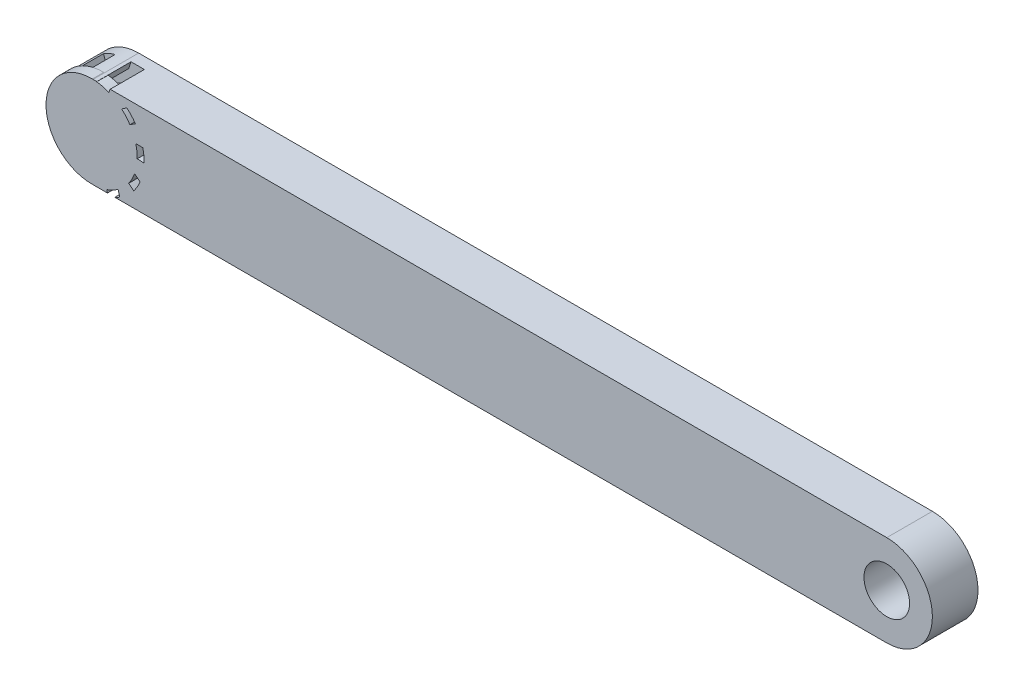
from build123d import *

# Parameters (mm, degrees)
SKETCH1_R           = 10
BOSS_EXTRUDE1_DEPTH = 20
BOSS_EXTRUDE2_DEPTH = 20
CUT_EXTRUDE1_DEPTH  = 15
SKETCH5_R           = 20
BOSS_EXTRUDE3_DEPTH = 5


with BuildPart() as part:
    # Sketch1 → Boss-Extrude1 (new body)
    with BuildSketch(Plane.XY):
        with BuildLine():
            Line((-71.370560529, 20), (276.629439471, 20))
            ThreePointArc((276.629439471, 20), (296.629439471, 0), (276.629439471, -20))
            Line((276.629439471, -20), (-71.370560529, -20))
            ThreePointArc((-71.370560529, -20), (-91.370560529, 0), (-71.370560529, 20))
        make_face()
        with Locations((-71.370560529, 0)):
            Circle(SKETCH1_R, mode=Mode.SUBTRACT)
        with Locations((276.629439471, 0)):
            Circle(SKETCH1_R, mode=Mode.SUBTRACT)
    extrude(amount=BOSS_EXTRUDE1_DEPTH)

    # Sketch2 → Boss-Extrude2 (add)
    with BuildSketch(Plane(origin=(0, 0, 0), x_dir=(-1, 0, 0), z_dir=(0, 0, -1))):
        with BuildLine():
            Line((71.370560529, -20), (71.370560529, -25))
            ThreePointArc((71.370560529, -25), (64.900084402, -24.148145657), (58.870560529, -21.650635095))
            Line((58.870560529, -21.650635095), (62.564306071, -17.956889553))
            ThreePointArc((62.564306071, -17.956889553), (66.850482602, -19.482527955), (71.370560529, -20))
        make_face()
    extrude(amount=BOSS_EXTRUDE2_DEPTH)

    # Sketch6 → Cut-Extrude1 (cut)
    with BuildSketch(Plane.XY.offset(20)):
        with BuildLine():
            ThreePointArc((-88.39401573, 13.427541495), (-86.445115044, 11.855559488), (-84.410885886, 10.395678313))
            ThreePointArc((-84.410885886, 10.395678313), (-82.694985814, 12.298884863), (-80.712431568, 13.922457124))
            ThreePointArc((-80.712431568, 13.922457124), (-81.560998495, 16.374699705), (-82.281198511, 18.867664093))
            ThreePointArc((-82.281198511, 18.867664093), (-79.798448631, 20.149575363), (-77.17323964, 21.106456352))
            ThreePointArc((-77.17323964, 21.106456352), (-76.520533705, 18.689161112), (-75.73290437, 16.312402533))
            ThreePointArc((-75.73290437, 16.312402533), (-73.22603531, 16.843548219), (-70.667803401, 16.991729622))
            ThreePointArc((-70.667803401, 16.991729622), (-69.912916442, 19.47441067), (-69.030242792, 21.914584175))
            ThreePointArc((-69.030242792, 21.914584175), (-66.268167407, 21.492348412), (-63.581888186, 20.723422265))
            ThreePointArc((-63.581888186, 20.723422265), (-64.474688485, 18.384138413), (-65.234506609, 15.998343424))
            ThreePointArc((-65.234506609, 15.998343424), (-62.894207335, 14.954548647), (-60.737455402, 13.570738932))
            ThreePointArc((-60.737455402, 13.570738932), (-58.667455717, 15.135558669), (-56.519059735, 16.59087795))
            ThreePointArc((-56.519059735, 16.59087795), (-54.532677763, 14.625774866), (-52.811395672, 12.424745236))
            ThreePointArc((-52.811395672, 12.424745236), (-54.908682835, 11.056999694), (-56.925723719, 9.57346089))
            ThreePointArc((-56.925723719, 9.57346089), (-55.645909011, 7.353419778), (-54.714442987, 4.966187222))
            ThreePointArc((-54.714442987, 4.966187222), (-52.120000099, 5.015437696), (-49.526496029, 4.930020252))
            ThreePointArc((-49.526496029, 4.930020252), (-49.074537869, 2.172652432), (-48.97572416, -0.619762172))
            ThreePointArc((-48.97572416, -0.619762172), (-51.476405776, -0.493537095), (-53.98022836, -0.508158314))
            ThreePointArc((-53.98022836, -0.508158314), (-54.249743937, -3.056465513), (-54.899352183, -5.535279212))
            ThreePointArc((-54.899352183, -5.535279212), (-52.771455094, -7.020410009), (-50.72347334, -8.613937617))
            ThreePointArc((-50.72347334, -8.613937617), (-51.978571647, -11.110349384), (-53.539969801, -13.427541495))
            ThreePointArc((-53.539969801, -13.427541495), (-55.488870486, -11.855559488), (-57.523099645, -10.395678313))
            ThreePointArc((-57.523099645, -10.395678313), (-59.238999716, -12.298884863), (-61.221553963, -13.922457124))
            ThreePointArc((-61.221553963, -13.922457124), (-60.372987036, -16.374699705), (-59.65278702, -18.867664093))
            ThreePointArc((-59.65278702, -18.867664093), (-62.1355369, -20.149575363), (-64.760745891, -21.106456352))
            ThreePointArc((-64.760745891, -21.106456352), (-65.413451825, -18.689161112), (-66.20108116, -16.312402533))
            ThreePointArc((-66.20108116, -16.312402533), (-68.707950221, -16.843548219), (-71.26618213, -16.991729622))
            ThreePointArc((-71.26618213, -16.991729622), (-72.021069089, -19.47441067), (-72.903742738, -21.914584175))
            ThreePointArc((-72.903742738, -21.914584175), (-75.665818123, -21.492348412), (-78.352097344, -20.723422265))
            ThreePointArc((-78.352097344, -20.723422265), (-77.459297045, -18.384138413), (-76.699478922, -15.998343424))
            ThreePointArc((-76.699478922, -15.998343424), (-79.039778195, -14.954548647), (-81.196530129, -13.570738932))
            ThreePointArc((-81.196530129, -13.570738932), (-83.266529813, -15.135558669), (-85.414925795, -16.59087795))
            ThreePointArc((-85.414925795, -16.59087795), (-87.401307767, -14.625774866), (-89.122589859, -12.424745236))
            ThreePointArc((-89.122589859, -12.424745236), (-87.025302696, -11.056999694), (-85.008261811, -9.57346089))
            ThreePointArc((-85.008261811, -9.57346089), (-86.28807652, -7.353419778), (-87.219542544, -4.966187222))
            ThreePointArc((-87.219542544, -4.966187222), (-89.813985431, -5.015437696), (-92.407489502, -4.930020252))
            ThreePointArc((-92.407489502, -4.930020252), (-92.859447662, -2.172652432), (-92.95826137, 0.619762172))
            ThreePointArc((-92.95826137, 0.619762172), (-90.457579755, 0.493537095), (-87.953757171, 0.508158314))
            ThreePointArc((-87.953757171, 0.508158314), (-87.684241594, 3.056465513), (-87.034633347, 5.535279212))
            ThreePointArc((-87.034633347, 5.535279212), (-89.162530436, 7.020410009), (-91.210512191, 8.613937617))
            ThreePointArc((-91.210512191, 8.613937617), (-89.955413884, 11.110349384), (-88.39401573, 13.427541495))
        make_face()
    extrude(amount=-CUT_EXTRUDE1_DEPTH, mode=Mode.SUBTRACT)

    # Sketch5 → Boss-Extrude3 (add)
    with BuildSketch(Plane.XY.offset(15)):
        with Locations((-72.002203934, 0)):
            Circle(SKETCH5_R)
    extrude(amount=BOSS_EXTRUDE3_DEPTH)


solid = part.part
